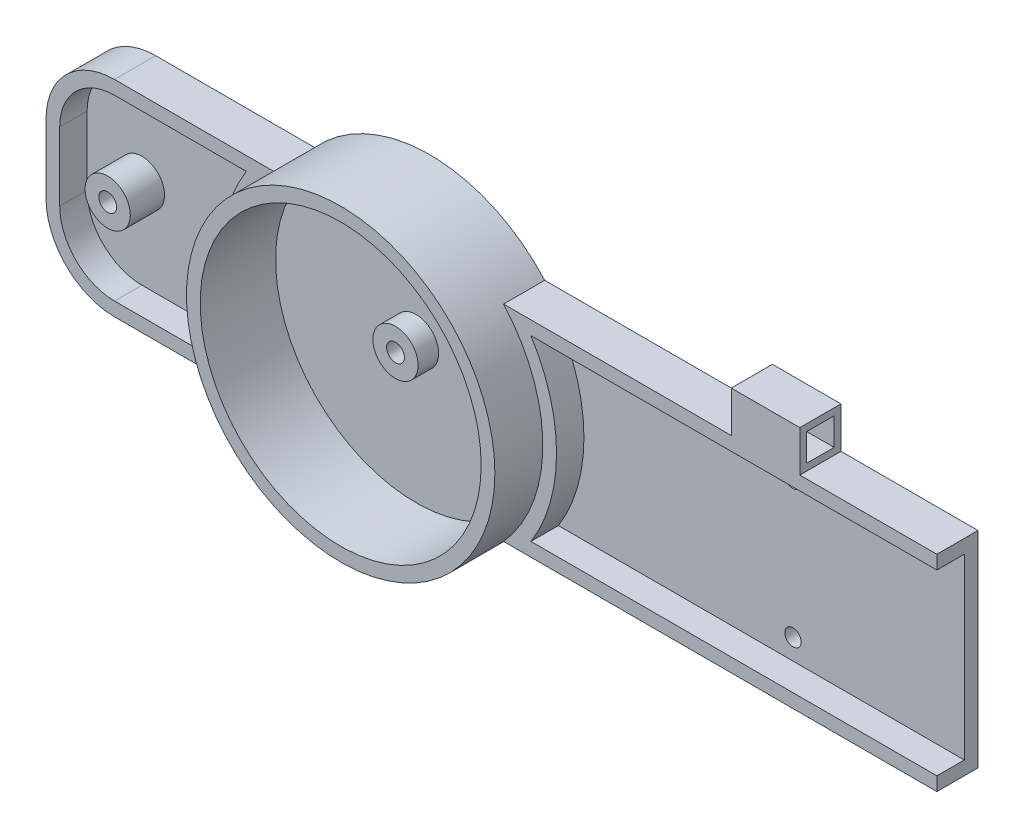
from build123d import *

# Parameters (mm, degrees)
SZKIC1_R                    = 22.5
DODANIE_WYCI_GNI_CIE2_DEPTH = 13
SZKIC2_W                    = 220
SZKIC2_H                    = 30
DODANIE_WYCI_GNI_CIE3_DEPTH = 6
ZAOKR_GLENIE1_R             = 10
SZKIC4_R                    = 20.5
WYTNIJ_WYCI_GNI_CIE3_DEPTH  = 11
WYTNIJ_WYCI_GNI_CIE2_DEPTH  = 4
WYTNIJ_WYCI_GNI_CIE4_REACH  = 173.975
SZKIC8_W                    = 23
SZKIC8_H                    = 14
SZKIC12_R                   = 3.3
DODANIE_WYCI_GNI_CIE4_DEPTH = 3
OTW_R_POD_RUB_M21_D         = 2.6
OTW_R_POD_RUB_M23_D         = 2.6
SZKIC14_R                   = 3.3
DODANIE_WYCI_GNI_CIE5_DEPTH = 5
OTW_R_POD_RUB_M24_D         = 2.6
SZKIC15_W                   = 6
SZKIC15_H                   = 6
SZKIC15_W_2                 = 4
SZKIC15_H_2                 = 4
DODANIE_WYCI_GNI_CIE6_DEPTH = 10
SZYK_LINIOWY1_COUNT         = 2
SZYK_LINIOWY1_PITCH         = 70
OTW_R_POD_RUB_M25_D         = 2.4


with BuildPart() as part:
    # Szkic1 → Dodanie-wyciągnięcie2 (new body)
    with BuildSketch(Plane.XY):
        with Locations(Location((0, 0, 0), (0, 0, 180))):
            Circle(SZKIC1_R)
    extrude(amount=DODANIE_WYCI_GNI_CIE2_DEPTH)

    # Szkic2 → Dodanie-wyciągnięcie3 (add)
    with BuildSketch(Plane.XY):
        with Locations((60, 0)):
            Rectangle(SZKIC2_W, SZKIC2_H)
    extrude(amount=DODANIE_WYCI_GNI_CIE3_DEPTH)

    # Zaokrąglenie1
    zaokr_glenie1_edges = [part.edges().sort_by_distance(p)[0] for p in [
        (170, 15, 3),
        (-50, -15, 3),
        (170, -15, 3),
        (-50, 15, 3),
    ]]
    fillet(zaokr_glenie1_edges, radius=ZAOKR_GLENIE1_R)

    # Szkic4 → Wytnij-wyciągnięcie3 (cut)
    with BuildSketch(Plane.XY.offset(13)):
        Circle(SZKIC4_R)
    extrude(amount=-WYTNIJ_WYCI_GNI_CIE3_DEPTH, mode=Mode.SUBTRACT)

    # Szkic3 → Wytnij-wyciągnięcie2 (cut)
    with BuildSketch(Plane.XY.offset(6)):
        with BuildLine():
            Line((168, -5), (168, 5))
            ThreePointArc((168, 5), (165.656854249, 10.656854249), (160, 13))
            Line((160, 13), (20.766559657, 13))
            ThreePointArc((20.766559657, 13), (24.5, 0), (20.766559657, -13))
            Line((20.766559657, -13), (160, -13))
            ThreePointArc((160, -13), (165.656854249, -10.656854249), (168, -5))
        make_face()
        with BuildLine():
            Line((-48, 5), (-48, -5))
            ThreePointArc((-48, -5), (-45.656854249, -10.656854249), (-40, -13))
            Line((-40, -13), (-20.766559657, -13))
            ThreePointArc((-20.766559657, -13), (-24.5, 0), (-20.766559657, 13))
            Line((-20.766559657, 13), (-40, 13))
            ThreePointArc((-40, 13), (-45.656854249, 10.656854249), (-48, 5))
        make_face()
    extrude(amount=-WYTNIJ_WYCI_GNI_CIE2_DEPTH, mode=Mode.SUBTRACT)

    # Szkic8 → Wytnij-wyciągnięcie4 (cut, up to next)
    with BuildSketch(Plane.XY, mode=Mode.PRIVATE) as wytnij_wyci_gni_cie4_sk1:
        with Locations((150, 0)):
            Rectangle(SZKIC8_W, SZKIC8_H)
    wytnij_wyci_gni_cie4_tool1 = extrude(wytnij_wyci_gni_cie4_sk1.sketch, amount=WYTNIJ_WYCI_GNI_CIE4_REACH, mode=Mode.PRIVATE) & part.part
    add(wytnij_wyci_gni_cie4_tool1.solids().sort_by_distance((150, 0, 0))[0], mode=Mode.SUBTRACT)

    # Szkic12 → Dodanie-wyciągnięcie4 (add)
    with BuildSketch(Plane.XY.offset(2)):
        Circle(SZKIC12_R)
    extrude(amount=DODANIE_WYCI_GNI_CIE4_DEPTH)

    # Otwór pod śrubę M21 (through all)
    with Locations(Plane(origin=(0, 0, 0), x_dir=(1, 0, 0), z_dir=(0, 0, -1))):
        with Locations((0, 0)):
            Hole(OTW_R_POD_RUB_M21_D / 2)

    # Otwór pod śrubę M23 (through all)
    with Locations(Plane(origin=(0, 0, 0), x_dir=(1, 0, 0), z_dir=(0, 0, -1))):
        with Locations((136, 0), (164, 0)):
            Hole(OTW_R_POD_RUB_M23_D / 2)

    # Szkic14 → Dodanie-wyciągnięcie5 (add)
    with BuildSketch(Plane.XY.offset(2)):
        with Locations((-40, 0)):
            Circle(SZKIC14_R)
    extrude(amount=DODANIE_WYCI_GNI_CIE5_DEPTH)

    # Otwór pod śrubę M24 (through all)
    with Locations(Plane(origin=(-40, 0, 0), x_dir=(-1, 0, 0), z_dir=(0, 0, -1))):
        with Locations((0, 0)):
            Hole(OTW_R_POD_RUB_M24_D / 2)

    # Szkic15 → Dodanie-wyciągnięcie6 (add)
    with BuildSketch(Plane(origin=(130, 0, 0), x_dir=(0, 0, -1), z_dir=(1, 0, 0))):
        with Locations((-3, 18)):
            Rectangle(SZKIC15_W, SZKIC15_H)
        with Locations((-3, 18)):
            Rectangle(SZKIC15_W_2, SZKIC15_H_2, mode=Mode.SUBTRACT)
    dodanie_wyci_gni_cie6 = extrude(amount=-DODANIE_WYCI_GNI_CIE6_DEPTH)

    # Szyk liniowy1: Dodanie-wyciągnięcie6 ×2
    with Locations(*[(-i * SZYK_LINIOWY1_PITCH, 0, 0) for i in range(1, SZYK_LINIOWY1_COUNT)]):
        add(dodanie_wyci_gni_cie6)

    # Otwór pod śrubę M25 (through all)
    with Locations(Plane.XY.offset(2)):
        with Locations((55, -10), (105, -10), (105, 10), (55, 10)):
            Hole(OTW_R_POD_RUB_M25_D / 2)

    # Cięcie powierzchnią1
    split(bisect_by=Plane(origin=(80, 0, 0), x_dir=(0, 0, -1), z_dir=(1, 0, 0)), keep=Keep.BOTTOM)


solid = part.part
